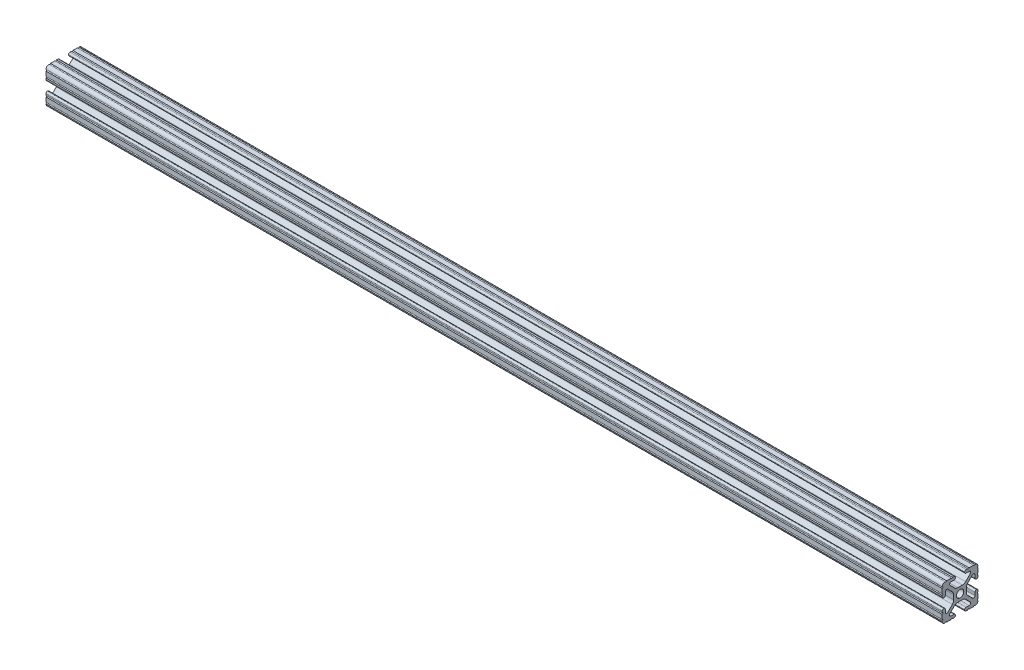
from build123d import *

# Parameters (mm, degrees)
SKETCH1_R           = 2.6035
BOSS_EXTRUDE1_DEPTH = 317.5


with BuildPart() as part:
    # Sketch1 → Boss-Extrude1 (new body, symmetric)
    with BuildSketch(Plane(origin=(0, 0, 0), x_dir=(0, 0, -1), z_dir=(1, 0, 0))):
        with BuildLine():
            Line((6.333126718, -12.7), (9.550443118, -12.7))
            ThreePointArc((9.550443118, -12.7), (10.058366869, -12.192000006), (10.566443095, -12.699847501))
            ThreePointArc((10.566443095, -12.699847501), (12.082537762, -12.08250727), (12.699846982, -10.566399977))
            ThreePointArc((12.699846982, -10.566399977), (12.192000006, -10.058323491), (12.7, -9.5504))
            Line((12.7, -9.5504), (12.7, -6.3330836))
            ThreePointArc((12.7, -6.3330836), (12.192, -5.8250836), (12.7, -5.3170836))
            Line((12.7, -5.3170836), (12.7, -4.287469289))
            ThreePointArc((12.7, -4.287469289), (12.39275138, -3.545705502), (11.650987593, -3.238456882))
            Line((11.650987593, -3.238456882), (11.539212407, -3.238456882))
            ThreePointArc((11.539212407, -3.238456882), (10.79744862, -3.545705502), (10.4902, -4.287469289))
            Line((10.4902, -4.287469289), (10.4902, -6.402089023))
            ThreePointArc((10.4902, -6.402089023), (9.856505071, -7.351067942), (8.737131347, -7.129408934))
            Line((8.737131347, -7.129408934), (5.441005833, -3.840816462))
            ThreePointArc((5.441005833, -3.840816462), (4.750877967, -2.809883091), (4.5085, -1.593185507))
            Line((4.5085, -1.593185507), (4.5085, 1.593185507))
            ThreePointArc((4.5085, 1.593185507), (4.750877967, 2.809883091), (5.441005833, 3.840816462))
            Line((5.441005833, 3.840816462), (8.737131347, 7.129408934))
            ThreePointArc((8.737131347, 7.129408934), (9.856505071, 7.351067942), (10.4902, 6.402089023))
            Line((10.4902, 6.402089023), (10.4902, 4.287469289))
            ThreePointArc((10.4902, 4.287469289), (10.79744862, 3.545705502), (11.539212407, 3.238456882))
            Line((11.539212407, 3.238456882), (11.650987593, 3.238456882))
            ThreePointArc((11.650987593, 3.238456882), (12.39275138, 3.545705502), (12.7, 4.287469289))
            Line((12.7, 4.287469289), (12.7, 5.3170836))
            ThreePointArc((12.7, 5.3170836), (12.192, 5.8250836), (12.7, 6.3330836))
            Line((12.7, 6.3330836), (12.7, 9.5504))
            ThreePointArc((12.7, 9.5504), (12.192000006, 10.058323491), (12.699846982, 10.566399977))
            ThreePointArc((12.699846982, 10.566399977), (12.082537762, 12.08250727), (10.566443095, 12.699847501))
            ThreePointArc((10.566443095, 12.699847501), (10.058366869, 12.192000006), (9.550443118, 12.7))
            Line((9.550443118, 12.7), (6.333126718, 12.7))
            ThreePointArc((6.333126718, 12.7), (5.825126718, 12.192), (5.317126718, 12.7))
            Line((5.317126718, 12.7), (4.287512407, 12.7))
            ThreePointArc((4.287512407, 12.7), (3.54574862, 12.39275138), (3.2385, 11.650987593))
            Line((3.2385, 11.650987593), (3.2385, 11.539212407))
            ThreePointArc((3.2385, 11.539212407), (3.54574862, 10.79744862), (4.287512407, 10.4902))
            Line((4.287512407, 10.4902), (6.476788598, 10.4902))
            ThreePointArc((6.476788598, 10.4902), (7.432222385, 9.85140422), (7.207036008, 8.724370562))
            Line((7.207036008, 8.724370562), (3.898272566, 5.423169045))
            ThreePointArc((3.898272566, 5.423169045), (2.869120213, 4.736787962), (1.655778399, 4.4958))
            Line((1.655778399, 4.4958), (-1.655778399, 4.4958))
            ThreePointArc((-1.655778399, 4.4958), (-2.869120213, 4.736787962), (-3.898272566, 5.423169045))
            Line((-3.898272566, 5.423169045), (-7.207036008, 8.724370562))
            ThreePointArc((-7.207036008, 8.724370562), (-7.432222385, 9.85140422), (-6.476788598, 10.4902))
            Line((-6.476788598, 10.4902), (-4.287512407, 10.4902))
            ThreePointArc((-4.287512407, 10.4902), (-3.54574862, 10.79744862), (-3.2385, 11.539212407))
            Line((-3.2385, 11.539212407), (-3.2385, 11.650987593))
            ThreePointArc((-3.2385, 11.650987593), (-3.54574862, 12.39275138), (-4.287512407, 12.7))
            Line((-4.287512407, 12.7), (-5.317126718, 12.7))
            ThreePointArc((-5.317126718, 12.7), (-5.825126718, 12.192), (-6.333126718, 12.7))
            Line((-6.333126718, 12.7), (-9.550443118, 12.7))
            ThreePointArc((-9.550443118, 12.7), (-10.058366869, 12.192000006), (-10.566443095, 12.699847501))
            ThreePointArc((-10.566443095, 12.699847501), (-12.082537762, 12.08250727), (-12.699846982, 10.566399977))
            ThreePointArc((-12.699846982, 10.566399977), (-12.192000006, 10.058323491), (-12.7, 9.5504))
            Line((-12.7, 9.5504), (-12.7, 6.3330836))
            ThreePointArc((-12.7, 6.3330836), (-12.192, 5.8250836), (-12.7, 5.3170836))
            Line((-12.7, 5.3170836), (-12.7, 4.287469289))
            ThreePointArc((-12.7, 4.287469289), (-12.39275138, 3.545705502), (-11.650987593, 3.238456882))
            Line((-11.650987593, 3.238456882), (-11.539212407, 3.238456882))
            ThreePointArc((-11.539212407, 3.238456882), (-10.79744862, 3.545705502), (-10.4902, 4.287469289))
            Line((-10.4902, 4.287469289), (-10.4902, 6.402089023))
            ThreePointArc((-10.4902, 6.402089023), (-9.856505071, 7.351067942), (-8.737131347, 7.129408934))
            Line((-8.737131347, 7.129408934), (-5.441005833, 3.840816462))
            ThreePointArc((-5.441005833, 3.840816462), (-4.750877967, 2.809883091), (-4.5085, 1.593185507))
            Line((-4.5085, 1.593185507), (-4.5085, -1.593185507))
            ThreePointArc((-4.5085, -1.593185507), (-4.750877967, -2.809883091), (-5.441005833, -3.840816462))
            Line((-5.441005833, -3.840816462), (-8.737131347, -7.129408934))
            ThreePointArc((-8.737131347, -7.129408934), (-9.856505071, -7.351067942), (-10.4902, -6.402089023))
            Line((-10.4902, -6.402089023), (-10.4902, -4.287469289))
            ThreePointArc((-10.4902, -4.287469289), (-10.79744862, -3.545705502), (-11.539212407, -3.238456882))
            Line((-11.539212407, -3.238456882), (-11.650987593, -3.238456882))
            ThreePointArc((-11.650987593, -3.238456882), (-12.39275138, -3.545705502), (-12.7, -4.287469289))
            Line((-12.7, -4.287469289), (-12.7, -5.3170836))
            ThreePointArc((-12.7, -5.3170836), (-12.192, -5.8250836), (-12.7, -6.3330836))
            Line((-12.7, -6.3330836), (-12.7, -9.5504))
            ThreePointArc((-12.7, -9.5504), (-12.192000006, -10.058323491), (-12.699846982, -10.566399977))
            ThreePointArc((-12.699846982, -10.566399977), (-12.082537762, -12.08250727), (-10.566443095, -12.699847501))
            ThreePointArc((-10.566443095, -12.699847501), (-10.058366869, -12.192000006), (-9.550443118, -12.7))
            Line((-9.550443118, -12.7), (-6.333126718, -12.7))
            ThreePointArc((-6.333126718, -12.7), (-5.825126718, -12.192), (-5.317126718, -12.7))
            Line((-5.317126718, -12.7), (-4.287512407, -12.7))
            ThreePointArc((-4.287512407, -12.7), (-3.54574862, -12.39275138), (-3.2385, -11.650987593))
            Line((-3.2385, -11.650987593), (-3.2385, -11.539212407))
            ThreePointArc((-3.2385, -11.539212407), (-3.54574862, -10.79744862), (-4.287512407, -10.4902))
            Line((-4.287512407, -10.4902), (-6.416408329, -10.4902))
            ThreePointArc((-6.416408329, -10.4902), (-7.41473083, -9.822813117), (-7.179650497, -8.645192506))
            Line((-7.179650497, -8.645192506), (-3.952270251, -5.423690499))
            ThreePointArc((-3.952270251, -5.423690499), (-2.922936451, -4.736929036), (-1.709253557, -4.4958))
            Line((-1.709253557, -4.4958), (1.709253557, -4.4958))
            ThreePointArc((1.709253557, -4.4958), (2.922936451, -4.736929036), (3.952270251, -5.423690499))
            Line((3.952270251, -5.423690499), (7.179650497, -8.645192506))
            ThreePointArc((7.179650497, -8.645192506), (7.41473083, -9.822813117), (6.416408329, -10.4902))
            Line((6.416408329, -10.4902), (4.287512407, -10.4902))
            ThreePointArc((4.287512407, -10.4902), (3.54574862, -10.79744862), (3.2385, -11.539212407))
            Line((3.2385, -11.539212407), (3.2385, -11.650987593))
            ThreePointArc((3.2385, -11.650987593), (3.54574862, -12.39275138), (4.287512407, -12.7))
            Line((4.287512407, -12.7), (5.317126718, -12.7))
            ThreePointArc((5.317126718, -12.7), (5.825126718, -12.192), (6.333126718, -12.7))
        make_face()
        Circle(SKETCH1_R, mode=Mode.SUBTRACT)
    extrude(amount=BOSS_EXTRUDE1_DEPTH, both=True)


solid = part.part
